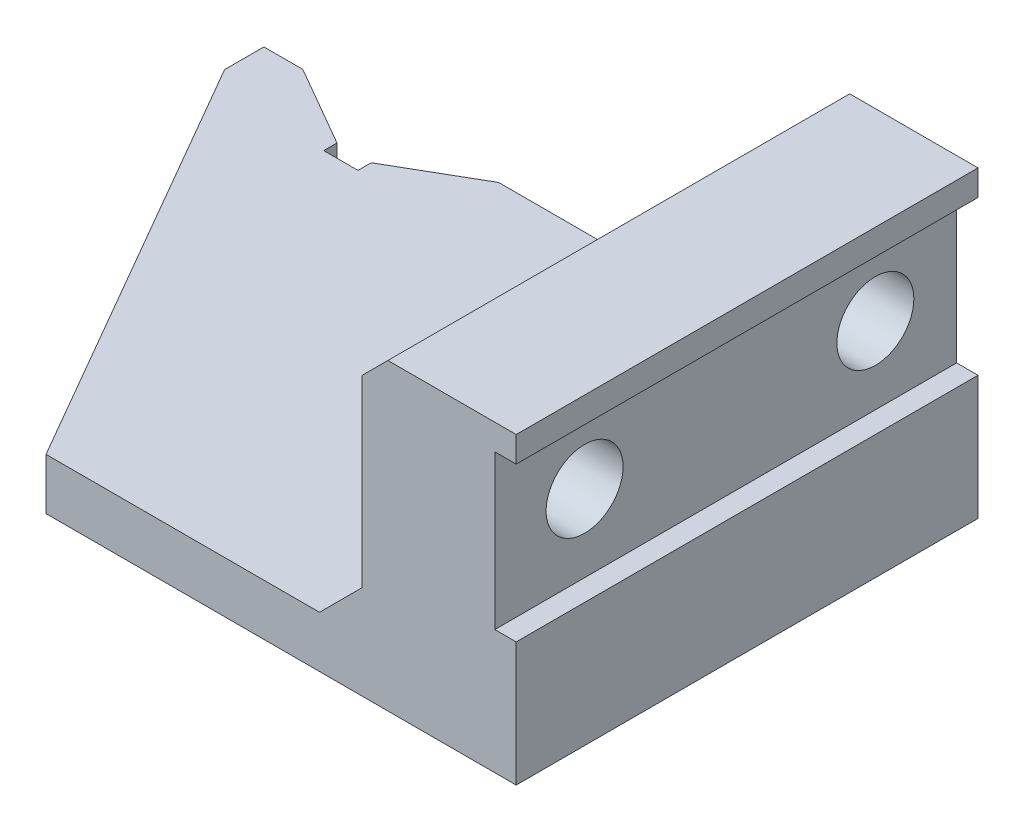
from build123d import *

# Parameters (mm, degrees)
AUFSATZ_LINEAR_AUSTRAGEN1_DEPTH = 54
SCHNITT_LINEAR_AUSTRAGEN1_DEPTH = 7
SCHNITT_LINEAR_AUSTRAGEN2_DEPTH = 7
SCHNITT_LINEAR_AUSTRAGEN3_REACH = 83
SKIZZE4_R                       = 4.5
SKIZZE5_R                       = 7.5
SCHNITT_LINEAR_AUSTRAGEN4_DEPTH = 8


with BuildPart() as part:
    # Skizze1 → Aufsatz-Linear austragen1 (new body)
    with BuildSketch(Plane.XY):
        Polygon((0, 6), (0, 0), (83.5, 0), (83.5, 14.5), (81, 14.5), (81, 32.5), (83.5, 32.5), (83.5, 35.5), (68.5, 35.5), (65.5, 32.5), (65.5, 11), (60.5, 6), align=None)
    extrude(amount=AUFSATZ_LINEAR_AUSTRAGEN1_DEPTH)

    # Skizze2 → Schnitt-Linear austragen1 (cut, through all)
    with BuildSketch(Plane(origin=(0, 6, 0), x_dir=(1, 0, 0), z_dir=(0, 1, 0))):
        Polygon((28.521103298, -54), (0, -4.6), (0, -54), align=None)
    extrude(amount=-SCHNITT_LINEAR_AUSTRAGEN1_DEPTH, mode=Mode.SUBTRACT)

    # Skizze3 → Schnitt-Linear austragen2 (cut, through all)
    with BuildSketch(Plane(origin=(0, 6, 0), x_dir=(1, 0, 0), z_dir=(0, 1, 0))):
        Polygon((14, -5.452863896), (14, -7), (18, -7), (18, -5.459056191), (27.455362685, 0), (4.555362685, 0), align=None)
    extrude(amount=-SCHNITT_LINEAR_AUSTRAGEN2_DEPTH, mode=Mode.SUBTRACT)

    # Skizze4 → Schnitt-Linear austragen3 (cut, up to next)
    with BuildSketch(Plane(origin=(81, 0, 0), x_dir=(0, 0, -1), z_dir=(1, 0, 0)), mode=Mode.PRIVATE) as schnitt_linear_austragen3_sk1:
        with Locations((-9.5, 23.5)):
            Circle(SKIZZE4_R)
    schnitt_linear_austragen3_tool1 = extrude(schnitt_linear_austragen3_sk1.sketch, amount=-SCHNITT_LINEAR_AUSTRAGEN3_REACH, mode=Mode.PRIVATE) & part.part
    add(schnitt_linear_austragen3_tool1.solids().sort_by_distance((81, 23.5, 9.5))[0], mode=Mode.SUBTRACT)
    # Skizze4 → Schnitt-Linear austragen3 (cut, up to next)
    with BuildSketch(Plane(origin=(81, 0, 0), x_dir=(0, 0, -1), z_dir=(1, 0, 0)), mode=Mode.PRIVATE) as schnitt_linear_austragen3_sk2:
        with Locations((-43.5, 23.5)):
            Circle(SKIZZE4_R)
    schnitt_linear_austragen3_tool2 = extrude(schnitt_linear_austragen3_sk2.sketch, amount=-SCHNITT_LINEAR_AUSTRAGEN3_REACH, mode=Mode.PRIVATE) & part.part
    add(schnitt_linear_austragen3_tool2.solids().sort_by_distance((81, 23.5, 43.5))[0], mode=Mode.SUBTRACT)

    # Skizze5 → Schnitt-Linear austragen4 (cut)
    with BuildSketch(Plane.ZY.offset(-65.5)):
        with Locations((43.5, 23.5)):
            Circle(SKIZZE5_R)
        with Locations((9.5, 23.5)):
            Circle(SKIZZE5_R)
    extrude(amount=-SCHNITT_LINEAR_AUSTRAGEN4_DEPTH, mode=Mode.SUBTRACT)


solid = part.part
